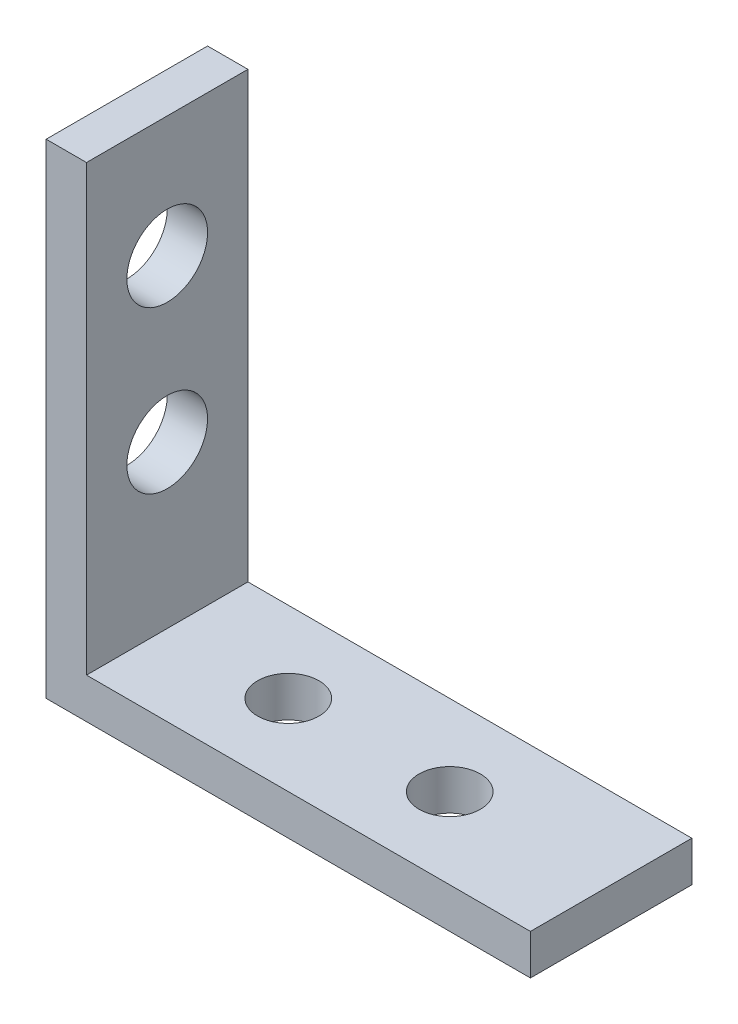
from build123d import *

# Parameters (mm, degrees)
BOSS_EXTRUDE1_DEPTH = 12.7
SKETCH2_R           = 2.413
CUT_EXTRUDE1_DEPTH  = 4.175
SKETCH3_R           = 3.175
CUT_EXTRUDE2_DEPTH  = 4.175


with BuildPart() as part:
    # Sketch1 → Boss-Extrude1 (new body)
    with BuildSketch(Plane.XY):
        Polygon((0, 0), (0, 38.1), (3.175, 38.1), (3.175, 3.175), (38.1, 3.175), (38.1, 0), align=None)
    extrude(amount=BOSS_EXTRUDE1_DEPTH)

    # Sketch2 → Cut-Extrude1 (cut, through all)
    with BuildSketch(Plane(origin=(0, 3.175, 0), x_dir=(1, 0, 0), z_dir=(0, 1, 0))):
        with Locations((12.7, -6.35)):
            Circle(SKETCH2_R)
        with Locations((25.4, -6.35)):
            Circle(SKETCH2_R)
    extrude(amount=-CUT_EXTRUDE1_DEPTH, mode=Mode.SUBTRACT)

    # Sketch3 → Cut-Extrude2 (cut, through all)
    with BuildSketch(Plane(origin=(3.175, 0, 0), x_dir=(0, 0, -1), z_dir=(1, 0, 0))):
        with Locations((-6.35, 28.575)):
            Circle(SKETCH3_R)
        with Locations((-6.35, 15.875)):
            Circle(SKETCH3_R)
    extrude(amount=-CUT_EXTRUDE2_DEPTH, mode=Mode.SUBTRACT)


solid = part.part
